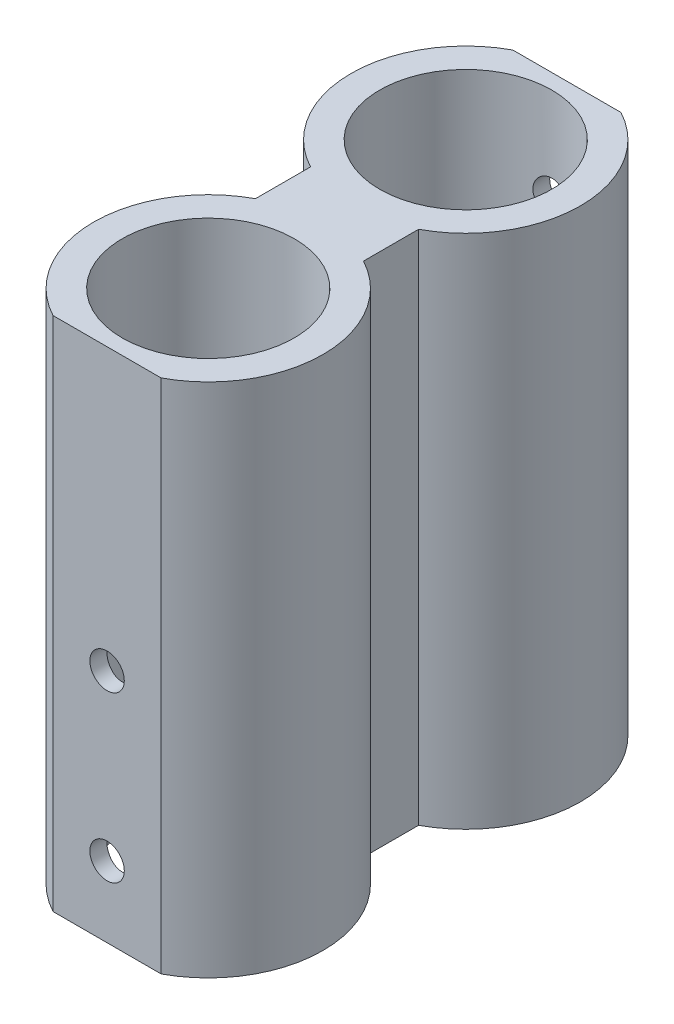
from build123d import *

# Parameters (mm, degrees)
BOSS_EXTRUDE2_DEPTH = 45
SKETCH5_R           = 7.5
CUT_EXTRUDE2_DEPTH  = 48
SKETCH6_R           = 1.5
CUT_EXTRUDE3_DEPTH  = 5
SKETCH7_R           = 1.5
CUT_EXTRUDE4_DEPTH  = 10


with BuildPart() as part:
    # Sketch1 → Boss-Extrude2 (new body)
    with BuildSketch(Plane(origin=(0, 0, 0), x_dir=(1, 0, 0), z_dir=(0, 1, 0))):
        with BuildLine():
            Line((-4.710946187, 8.820826833), (4.710946187, 8.820826833))
            ThreePointArc((4.710946187, 8.820826833), (10, 0), (4.710946187, -8.820826833))
            Line((4.710946187, -8.820826833), (4.710946187, -13.627089834))
            ThreePointArc((4.710946187, -13.627089834), (10, -22.447916667), (4.710946187, -31.2687435))
            Line((4.710946187, -31.2687435), (-4.710946187, -31.2687435))
            ThreePointArc((-4.710946187, -31.2687435), (-10, -22.447916667), (-4.710946187, -13.627089834))
            Line((-4.710946187, -13.627089834), (-4.710946187, -8.820826833))
            ThreePointArc((-4.710946187, -8.820826833), (-10, 0), (-4.710946187, 8.820826833))
        make_face()
    extrude(amount=BOSS_EXTRUDE2_DEPTH)

    # Sketch5 → Cut-Extrude2 (cut)
    with BuildSketch(Plane(origin=(0, 45, 0), x_dir=(1, 0, 0), z_dir=(0, 1, 0))):
        Circle(SKETCH5_R)
        with Locations((0, -22.447916667)):
            Circle(SKETCH5_R)
    extrude(amount=-CUT_EXTRUDE2_DEPTH, mode=Mode.SUBTRACT)

    # Sketch6 → Cut-Extrude3 (cut)
    with BuildSketch(Plane.XY.offset(31.2687435)):
        with Locations((0, 20.532693815)):
            Circle(SKETCH6_R)
        with Locations((0, 6.178945615)):
            Circle(SKETCH6_R)
    extrude(amount=-CUT_EXTRUDE3_DEPTH, mode=Mode.SUBTRACT)

    # Sketch7 → Cut-Extrude4 (cut)
    with BuildSketch(Plane(origin=(0, 0, -8.820826833), x_dir=(-1, 0, 0), z_dir=(0, 0, -1))):
        with Locations((0, 36.852392065)):
            Circle(SKETCH7_R)
    extrude(amount=-CUT_EXTRUDE4_DEPTH, mode=Mode.SUBTRACT)


solid = part.part
